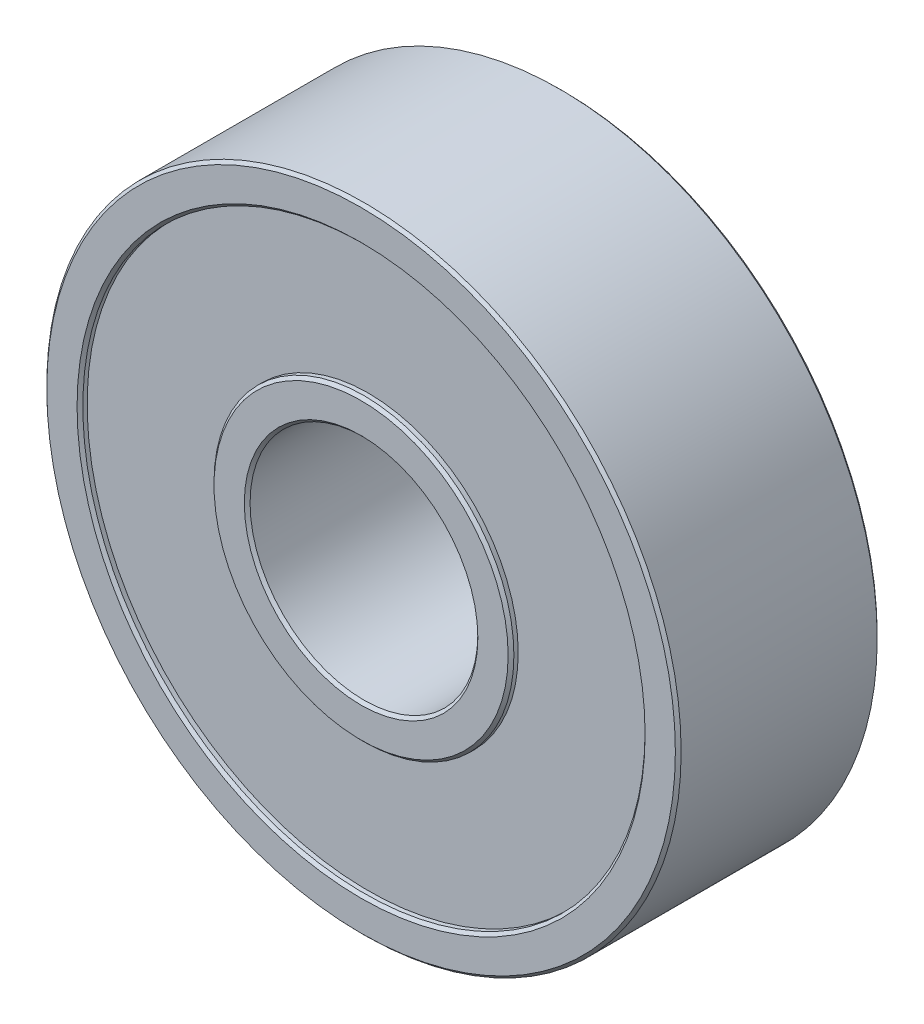
from build123d import *

# Parameters (mm, degrees)
SKETCH1_R                = 11
SKETCH1_R_2              = 3.95
BOSS_EXTRUDE1_DEPTH      = 3.5
BOSS_EXTRUDE1_DEPTH_BACK = 3.5
CUT_EXTRUDE1_START       = -3.5
SKETCH2_R                = 9.75
SKETCH2_R_2              = 5.2
CUT_EXTRUDE1_DEPTH       = 0.25
CUT_EXTRUDE2_START       = 3.5
SKETCH2_2_R              = 9.75
SKETCH2_2_R_2            = 5.2
CUT_EXTRUDE2_DEPTH       = 0.25
CHAMFER1_SIZE            = 0.1


with BuildPart() as part:
    # Sketch1 → Boss-Extrude1 (new body, two sides)
    with BuildSketch(Plane.XY) as boss_extrude1_sk:
        Circle(SKETCH1_R)
        Circle(SKETCH1_R_2, mode=Mode.SUBTRACT)
    extrude(amount=BOSS_EXTRUDE1_DEPTH)
    extrude(boss_extrude1_sk.sketch, amount=-BOSS_EXTRUDE1_DEPTH_BACK)

    # Sketch2 → Cut-Extrude1 (cut)
    with BuildSketch(Plane.XY.offset(CUT_EXTRUDE1_START)):
        Circle(SKETCH2_R)
        Circle(SKETCH2_R_2, mode=Mode.SUBTRACT)
    extrude(amount=CUT_EXTRUDE1_DEPTH, mode=Mode.SUBTRACT)

    # Sketch2_2 → Cut-Extrude2 (cut)
    with BuildSketch(Plane.XY.offset(CUT_EXTRUDE2_START)):
        Circle(SKETCH2_2_R)
        Circle(SKETCH2_2_R_2, mode=Mode.SUBTRACT)
    extrude(amount=-CUT_EXTRUDE2_DEPTH, mode=Mode.SUBTRACT)

    # Chamfer1
    chamfer1_edges = [part.edges().sort_by_distance(p)[0] for p in [
        (-5.2, 0, -3.5),
        (-9.75, 0, -3.5),
        (-9.75, 0, 3.5),
        (-5.2, 0, 3.5),
        (-11, 0, -3.5),
        (-3.95, 0, -3.5),
        (-11, 0, 3.5),
        (-3.95, 0, 3.5),
    ]]
    chamfer(chamfer1_edges, length=CHAMFER1_SIZE)


solid = part.part
